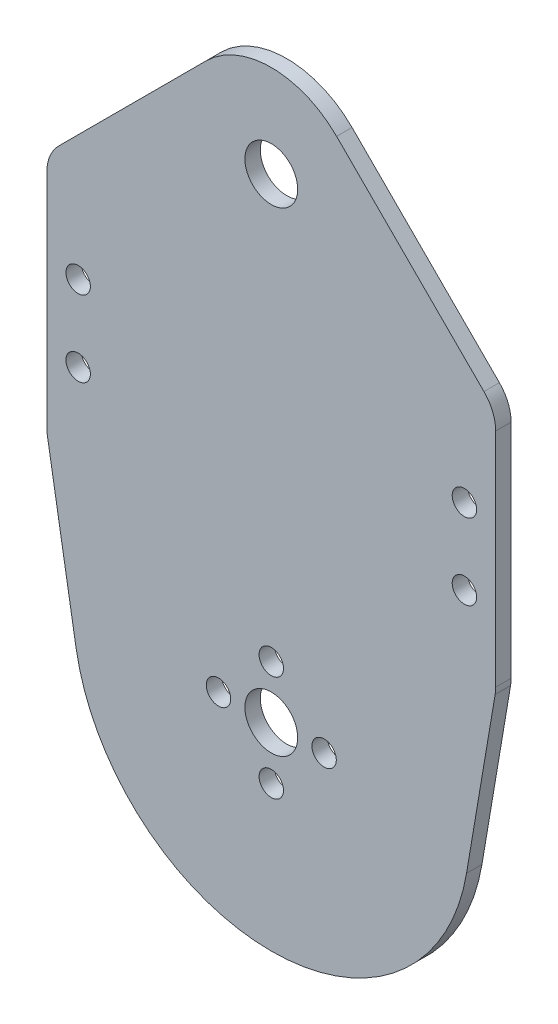
from build123d import *

# Parameters (mm, degrees)
SKETCH1_R           = 4
SKETCH1_R_2         = 1.85
BOSS_EXTRUDE1_DEPTH = 2.3368


with BuildPart() as part:
    # Sketch1 → Boss-Extrude1 (new body)
    with BuildSketch(Plane.XY):
        with BuildLine():
            Line((-29.579916475, -5.002853321), (-33.915090683, 20.629337502))
            ThreePointArc((-33.915090683, 20.629337502), (-33.978735385, 21.133158673), (-34, 21.640538448))
            Line((-34, 21.640538448), (-34, 55.247304326))
            ThreePointArc((-34, 55.247304326), (-33.538424872, 57.567799195), (-32.223970118, 59.535019756))
            Line((-32.223970118, 59.535019756), (-9.899494937, 81.859494937))
            ThreePointArc((-9.899494937, 81.859494937), (0, 85.96), (9.899494937, 81.859494937))
            Line((9.899494937, 81.859494937), (32.223970118, 59.535019756))
            ThreePointArc((32.223970118, 59.535019756), (33.538424872, 57.567799195), (34, 55.247304326))
            Line((34, 55.247304326), (34, 21.640538448))
            ThreePointArc((34, 21.640538448), (33.978735385, 21.133158673), (33.915090683, 20.629337502))
            Line((33.915090683, 20.629337502), (29.579916475, -5.002853321))
            ThreePointArc((29.579916475, -5.002853321), (0, -30), (-29.579916475, -5.002853321))
        make_face()
        Circle(SKETCH1_R, mode=Mode.SUBTRACT)
        with Locations((0, 8)):
            Circle(SKETCH1_R_2, mode=Mode.SUBTRACT)
        with Locations((-8, 0)):
            Circle(SKETCH1_R_2, mode=Mode.SUBTRACT)
        with Locations((0, -8)):
            Circle(SKETCH1_R_2, mode=Mode.SUBTRACT)
        with Locations((8, 0)):
            Circle(SKETCH1_R_2, mode=Mode.SUBTRACT)
        with Locations((0, 71.96)):
            Circle(SKETCH1_R, mode=Mode.SUBTRACT)
        with Locations((-29.2625, 32)):
            Circle(SKETCH1_R_2, mode=Mode.SUBTRACT)
        with Locations((29.2625, 43.5)):
            Circle(SKETCH1_R_2, mode=Mode.SUBTRACT)
        with Locations((29.2625, 32)):
            Circle(SKETCH1_R_2, mode=Mode.SUBTRACT)
        with Locations((-29.2625, 43.5)):
            Circle(SKETCH1_R_2, mode=Mode.SUBTRACT)
    extrude(amount=BOSS_EXTRUDE1_DEPTH)


solid = part.part
